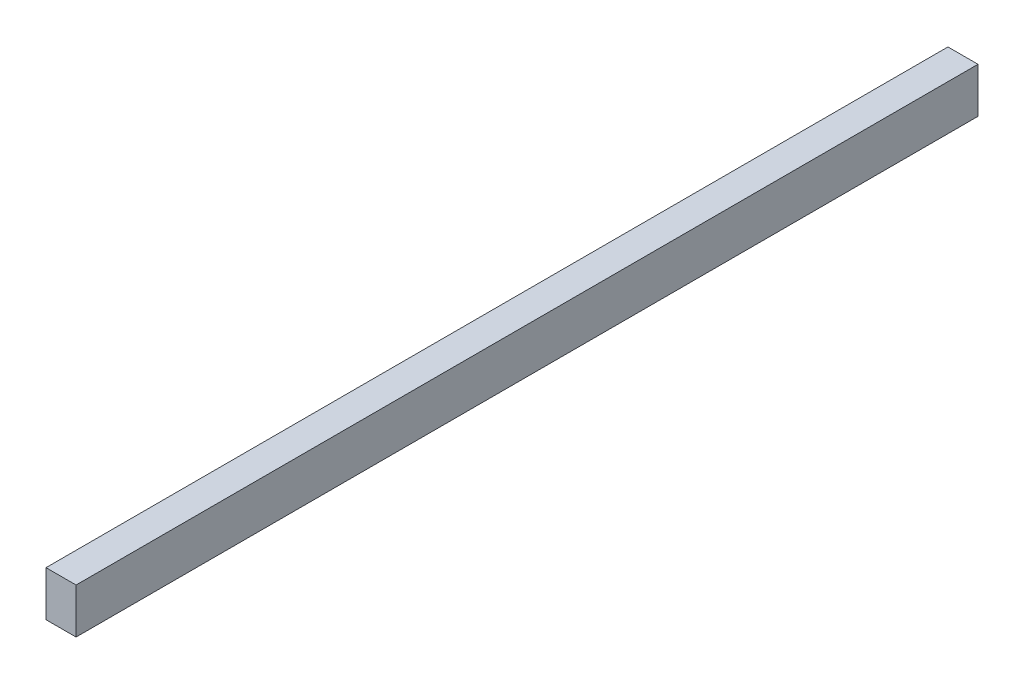
from build123d import *

# Parameters (mm, degrees)
SKETCH_1_W      = 10
SKETCH_1_H      = 15
EXTRUDE_1_DEPTH = 300


with BuildPart() as part:
    # Эскиз1 → Бобышка-Вытянуть1 (new body)
    with BuildSketch(Plane.XY):
        with Locations((5, 7.5)):
            Rectangle(SKETCH_1_W, SKETCH_1_H)
    extrude(amount=EXTRUDE_1_DEPTH)


solid = part.part
